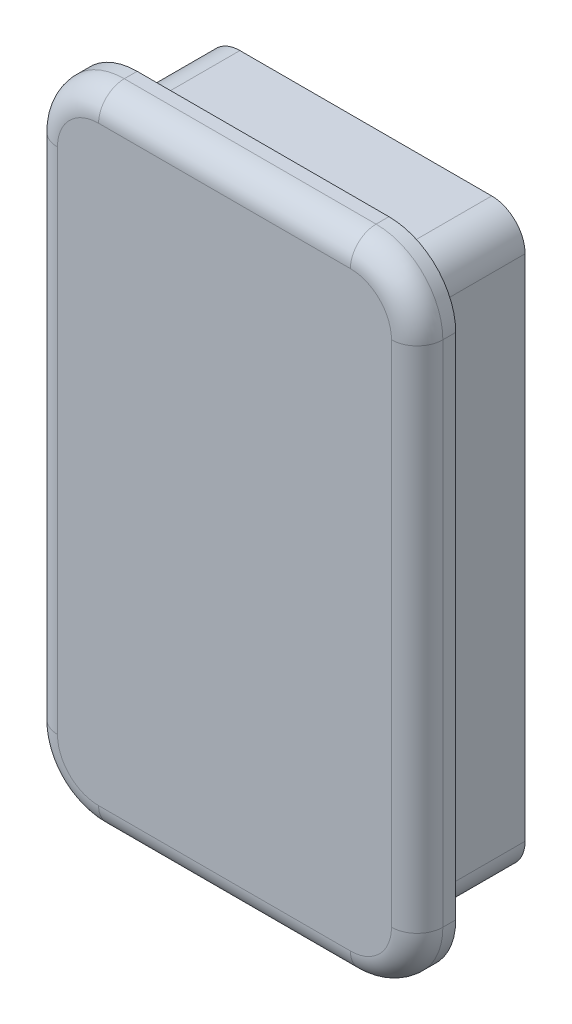
from build123d import *

# Parameters (mm, degrees)
BOSS_EXTRUDE1_DEPTH = 8
BOSS_EXTRUDE3_DEPTH = 3
FILLET1_R           = 2
SHELL1_T            = -2


with BuildPart() as part:
    # Sketch1 → Boss-Extrude1 (new body)
    with BuildSketch(Plane.XY):
        with BuildLine():
            Line((-9.8, -22.4), (9.8, -22.4))
            ThreePointArc((9.8, -22.4), (11.638477631, -21.638477631), (12.4, -19.8))
            Line((12.4, -19.8), (12.4, 19.8))
            ThreePointArc((12.4, 19.8), (11.638477631, 21.638477631), (9.8, 22.4))
            Line((9.8, 22.4), (-9.8, 22.4))
            ThreePointArc((-9.8, 22.4), (-11.638477631, 21.638477631), (-12.4, 19.8))
            Line((-12.4, 19.8), (-12.4, -19.8))
            ThreePointArc((-12.4, -19.8), (-11.638477631, -21.638477631), (-9.8, -22.4))
        make_face()
    extrude(amount=-BOSS_EXTRUDE1_DEPTH)

    # Sketch3 → Boss-Extrude3 (add)
    with BuildSketch(Plane.XY):
        with BuildLine():
            Line((-9.8, -25), (9.8, -25))
            ThreePointArc((9.8, -25), (13.476955262, -23.476955262), (15, -19.8))
            Line((15, -19.8), (15, 19.8))
            ThreePointArc((15, 19.8), (13.476955262, 23.476955262), (9.8, 25))
            Line((9.8, 25), (-9.8, 25))
            ThreePointArc((-9.8, 25), (-13.476955262, 23.476955262), (-15, 19.8))
            Line((-15, 19.8), (-15, -19.8))
            ThreePointArc((-15, -19.8), (-13.476955262, -23.476955262), (-9.8, -25))
        make_face()
    extrude(amount=BOSS_EXTRUDE3_DEPTH)

    # Fillet1
    fillet1_edges = [part.edges().sort_by_distance(p)[0] for p in [
        (13.476955262, 23.476955262, 3),
        (0, 25, 3),
        (-13.476955262, 23.476955262, 3),
        (-15, 0, 3),
        (-13.476955262, -23.476955262, 3),
        (0, -25, 3),
        (13.476955262, -23.476955262, 3),
        (15, 0, 3),
    ]]
    fillet(fillet1_edges, radius=FILLET1_R)

    # Shell1
    shell1_openings = [part.faces().sort_by_distance(p)[0] for p in [
        (0, 0, -8),
    ]]
    offset(amount=SHELL1_T, openings=shell1_openings, kind=Kind.INTERSECTION)


solid = part.part
